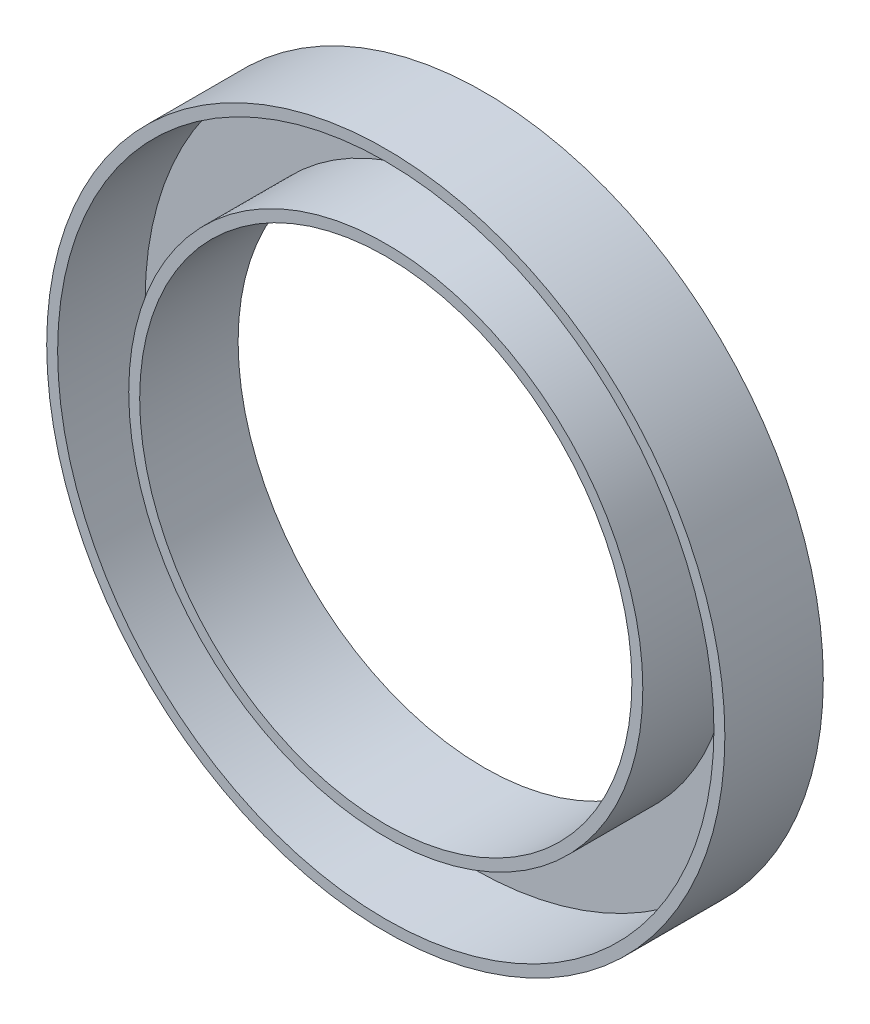
from build123d import *

# Parameters (mm, degrees)
SKETCH_1_R      = 31
SKETCH_1_R_2    = 22.5
EXTRUDE_1_DEPTH = 9
SHELL_1_T       = -1


with BuildPart() as part:
    # 草图1 → 凸台-拉伸1 (new body)
    with BuildSketch(Plane.XY):
        Circle(SKETCH_1_R)
        Circle(SKETCH_1_R_2, mode=Mode.SUBTRACT)
    extrude(amount=EXTRUDE_1_DEPTH)

    # 抽壳1
    shell_1_openings = [part.faces().sort_by_distance(p)[0] for p in [
        (-30.123187591, 0, 9),
    ]]
    offset(amount=SHELL_1_T, openings=shell_1_openings, kind=Kind.INTERSECTION)


solid = part.part
